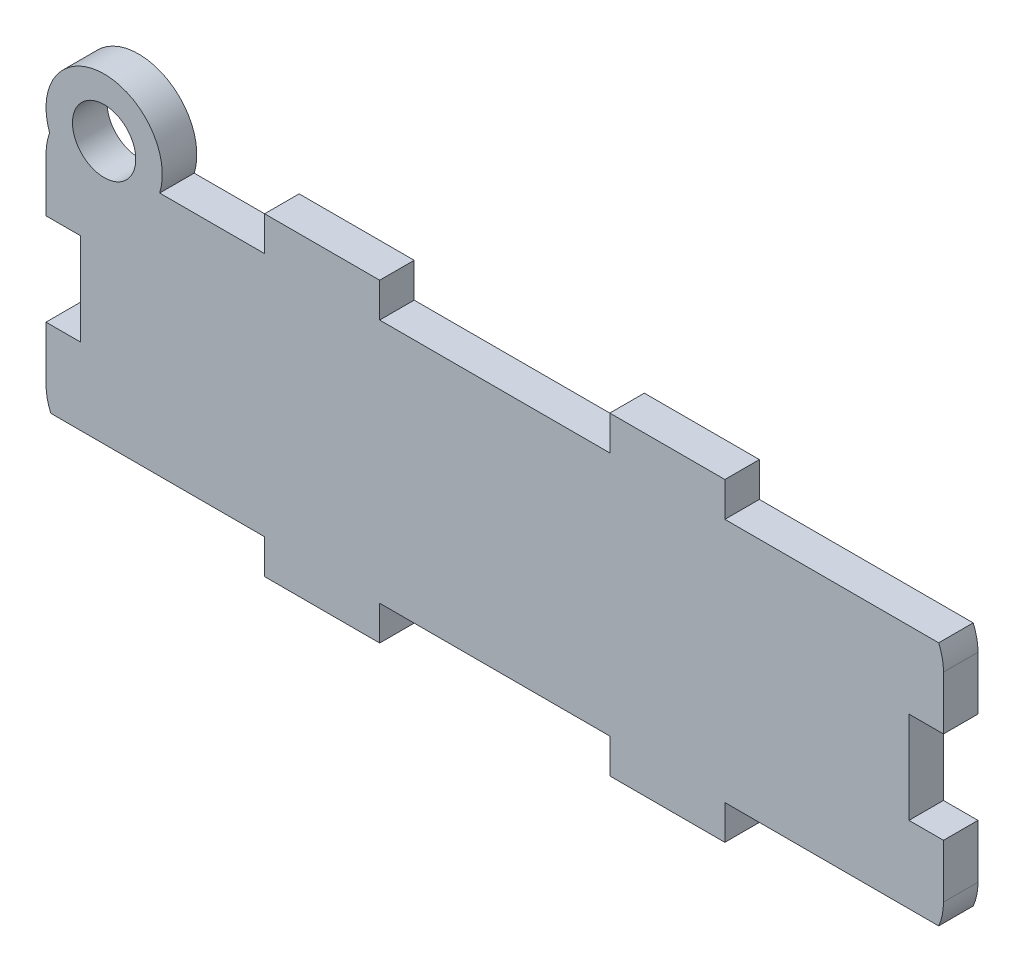
from build123d import *

# Parameters (mm, degrees)
BOSS_EXTRUDE1_DEPTH = 3
SKETCH3_R           = 5.053902861
SKETCH3_R_2         = 2.749769833
BOSS_EXTRUDE3_DEPTH = 3
CUT_EXTRUDE1_DEPTH  = 3
SKETCH5_W           = 3
SKETCH5_H           = 8
CUT_EXTRUDE2_DEPTH  = 3


with BuildPart() as part:
    # Sketch1 → Boss-Extrude1 (new body)
    with BuildSketch(Plane.XY):
        with BuildLine():
            Line((-7, -3), (3, -3))
            Line((3, -3), (3, 0))
            Line((3, 0), (23, 0))
            Line((23, 0), (23, -3))
            Line((23, -3), (33, -3))
            Line((33, -3), (33, 0))
            Line((33, 0), (51.582575695, 0))
            ThreePointArc((51.582575695, 0), (51.894531565, 0.978451782), (52, 2))
            Line((52, 2), (52, 19.311841589))
            ThreePointArc((52, 19.311841589), (51.894531565, 20.333389808), (51.582575695, 21.311841589))
            Line((51.582575695, 21.311841589), (33, 21.311841589))
            Line((33, 21.311841589), (33, 24.311841589))
            Line((33, 24.311841589), (23, 24.311841589))
            Line((23, 24.311841589), (23, 21.311841589))
            Line((23, 21.311841589), (3, 21.311841589))
            Line((3, 21.311841589), (3, 24.311841589))
            Line((3, 24.311841589), (-7, 24.311841589))
            Line((-7, 24.311841589), (-7, 21.311841589))
            Line((-7, 21.311841589), (-25.582575695, 21.311841589))
            ThreePointArc((-25.582575695, 21.311841589), (-25.894531565, 20.333389808), (-26, 19.311841589))
            Line((-26, 19.311841589), (-26, 2))
            ThreePointArc((-26, 2), (-25.894531565, 0.978451782), (-25.582575695, 0))
            Line((-25.582575695, 0), (-7, 0))
            Line((-7, 0), (-7, -3))
        make_face()
    extrude(amount=BOSS_EXTRUDE1_DEPTH)

    # Sketch3 → Boss-Extrude3 (add)
    with BuildSketch(Plane(origin=(0, 0, 0), x_dir=(-1, 0, 0), z_dir=(0, 0, -1))):
        with Locations((20.946097139, 22.811841589)):
            Circle(SKETCH3_R)
        with Locations((20.946097139, 22.811841589)):
            Circle(SKETCH3_R_2, mode=Mode.SUBTRACT)
    extrude(amount=-BOSS_EXTRUDE3_DEPTH)

    # Sketch4 → Cut-Extrude1 (cut)
    with BuildSketch(Plane(origin=(0, 0, 0), x_dir=(-1, 0, 0), z_dir=(0, 0, -1))):
        with BuildLine():
            Line((23.250708633, 21.311841589), (18.641485645, 21.311841589))
            ThreePointArc((18.641485645, 21.311841589), (20.946097139, 20.062071756), (23.250708633, 21.311841589))
        make_face()
    extrude(amount=-CUT_EXTRUDE1_DEPTH, mode=Mode.SUBTRACT)

    # Sketch5 → Cut-Extrude2 (cut)
    with BuildSketch(Plane(origin=(0, 0, 0), x_dir=(-1, 0, 0), z_dir=(0, 0, -1))):
        with Locations((24.5, 10.655920795)):
            Rectangle(SKETCH5_W, SKETCH5_H)
        with Locations((-50.5, 10.655920795)):
            Rectangle(SKETCH5_W, SKETCH5_H)
    extrude(amount=-CUT_EXTRUDE2_DEPTH, mode=Mode.SUBTRACT)


solid = part.part
